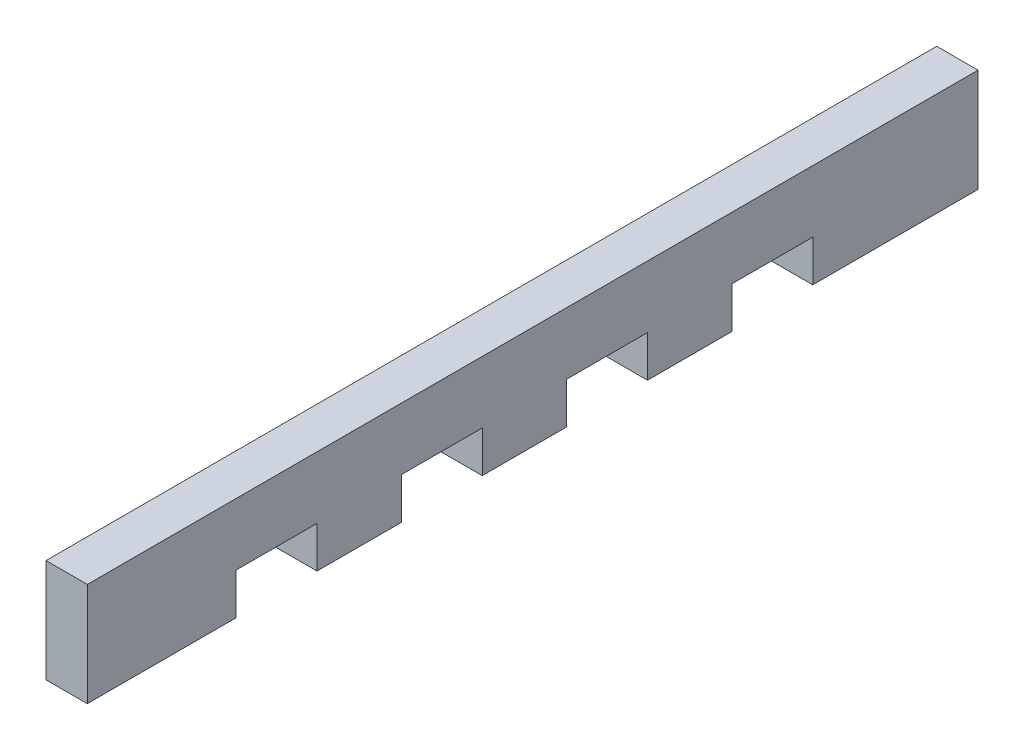
from build123d import *

# Parameters (mm, degrees)
BOSS_EXTRUDE1_DEPTH = 6.35


with BuildPart() as part:
    # Sketch1 → Boss-Extrude1 (new body)
    with BuildSketch(Plane(origin=(0, 0, 0), x_dir=(0, 0, -1), z_dir=(1, 0, 0))):
        Polygon((0, 0), (22.86, 0), (22.86, 6.35), (35.306, 6.35), (35.306, 0), (48.26, 0), (48.26, 6.35), (60.706, 6.35), (60.706, 0), (73.66, 0), (73.66, 6.35), (86.106, 6.35), (86.106, 0), (99.06, 0), (99.06, 6.35), (111.506, 6.35), (111.506, 0), (136.906, 0), (136.906, 15.875), (0, 15.875), align=None)
    extrude(amount=BOSS_EXTRUDE1_DEPTH)


solid = part.part
